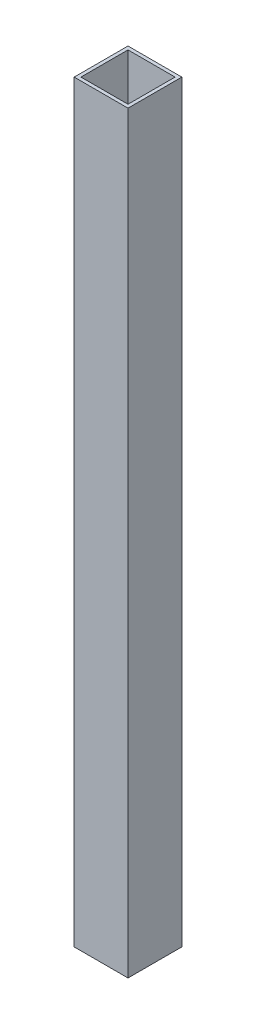
from build123d import *

# Parameters (mm, degrees)
SKETCH1_W           = 25.4
SKETCH1_H           = 25.4
SKETCH1_W_2         = 22.225
SKETCH1_H_2         = 22.225
BOSS_EXTRUDE1_DEPTH = 355.6


with BuildPart() as part:
    # Sketch1 → Boss-Extrude1 (new body)
    with BuildSketch(Plane(origin=(0, 0, 0), x_dir=(1, 0, 0), z_dir=(0, 1, 0))):
        Rectangle(SKETCH1_W, SKETCH1_H)
        Rectangle(SKETCH1_W_2, SKETCH1_H_2, mode=Mode.SUBTRACT)
    extrude(amount=BOSS_EXTRUDE1_DEPTH)


solid = part.part
